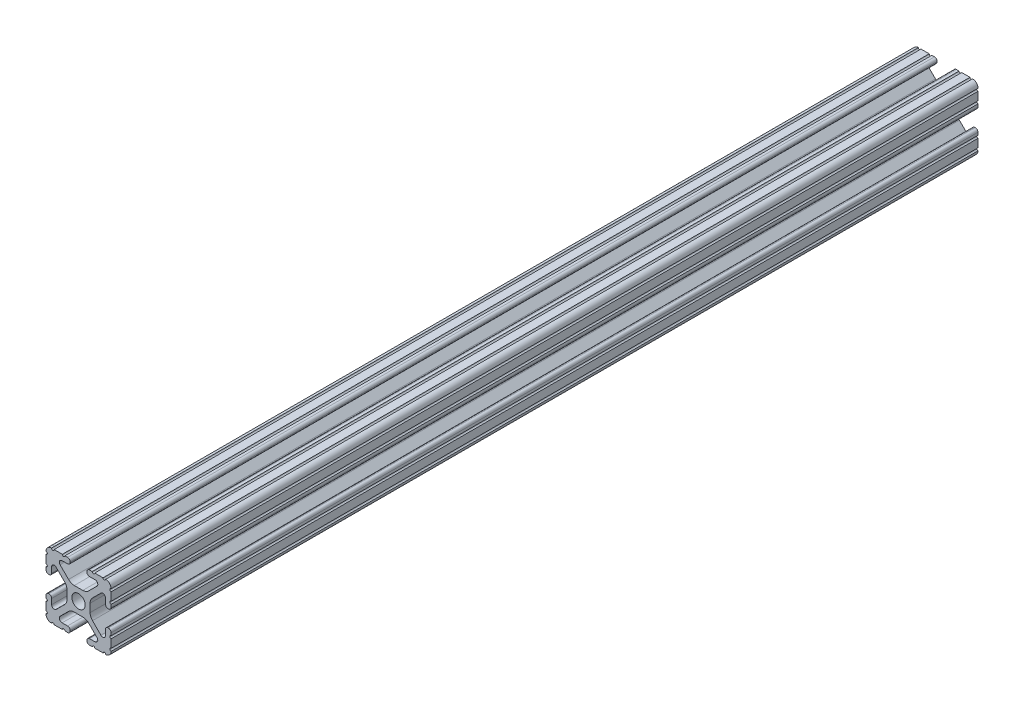
from build123d import *

# Parameters (mm, degrees)
SKETCH1_R               = 2.6035
BOSS_EXTRUDE1_DEPTH     = 457.2
CUT_EXTRUDE2_DEPTH      = 4.318
CUT_EXTRUDE2_DEPTH_BACK = 26.924
SKETCH4_W               = 324.910304918
SKETCH4_H               = 30.197320423
CUT_EXTRUDE3_DEPTH      = 1
CUT_EXTRUDE3_DEPTH_BACK = 26.4


with BuildPart() as part:
    # Sketch1 → Boss-Extrude1 (new body, symmetric)
    with BuildSketch(Plane.XY):
        with BuildLine():
            Line((-7.179650497, -8.645192506), (-3.952270251, -5.423690499))
            ThreePointArc((-3.952270251, -5.423690499), (-2.922936451, -4.736929036), (-1.709253557, -4.4958))
            Line((-1.709253557, -4.4958), (1.709253557, -4.4958))
            ThreePointArc((1.709253557, -4.4958), (2.922936451, -4.736929036), (3.952270251, -5.423690499))
            Line((3.952270251, -5.423690499), (7.179650497, -8.645192506))
            ThreePointArc((7.179650497, -8.645192506), (7.41473083, -9.822813117), (6.416408329, -10.4902))
            Line((6.416408329, -10.4902), (4.287512407, -10.4902))
            ThreePointArc((4.287512407, -10.4902), (3.54574862, -10.79744862), (3.2385, -11.539212407))
            Line((3.2385, -11.539212407), (3.2385, -11.650987593))
            ThreePointArc((3.2385, -11.650987593), (3.54574862, -12.39275138), (4.287512407, -12.7))
            Line((4.287512407, -12.7), (5.317126718, -12.7))
            ThreePointArc((5.317126718, -12.7), (5.825126718, -12.192), (6.333126718, -12.7))
            Line((6.333126718, -12.7), (9.550443118, -12.7))
            ThreePointArc((9.550443118, -12.7), (10.058366869, -12.192000006), (10.566443095, -12.699847501))
            ThreePointArc((10.566443095, -12.699847501), (12.082537762, -12.08250727), (12.699846982, -10.566399977))
            ThreePointArc((12.699846982, -10.566399977), (12.192000006, -10.058323491), (12.7, -9.5504))
            Line((12.7, -9.5504), (12.7, -6.3330836))
            ThreePointArc((12.7, -6.3330836), (12.192, -5.8250836), (12.7, -5.3170836))
            Line((12.7, -5.3170836), (12.7, -4.287469289))
            ThreePointArc((12.7, -4.287469289), (12.39275138, -3.545705502), (11.650987593, -3.238456882))
            Line((11.650987593, -3.238456882), (11.539212407, -3.238456882))
            ThreePointArc((11.539212407, -3.238456882), (10.79744862, -3.545705502), (10.4902, -4.287469289))
            Line((10.4902, -4.287469289), (10.4902, -6.402089023))
            ThreePointArc((10.4902, -6.402089023), (9.856505071, -7.351067942), (8.737131347, -7.129408934))
            Line((8.737131347, -7.129408934), (5.441005833, -3.840816462))
            ThreePointArc((5.441005833, -3.840816462), (4.750877967, -2.809883091), (4.5085, -1.593185507))
            Line((4.5085, -1.593185507), (4.5085, 1.593185507))
            ThreePointArc((4.5085, 1.593185507), (4.750877967, 2.809883091), (5.441005833, 3.840816462))
            Line((5.441005833, 3.840816462), (8.737131347, 7.129408934))
            ThreePointArc((8.737131347, 7.129408934), (9.856505071, 7.351067942), (10.4902, 6.402089023))
            Line((10.4902, 6.402089023), (10.4902, 4.287469289))
            ThreePointArc((10.4902, 4.287469289), (10.79744862, 3.545705502), (11.539212407, 3.238456882))
            Line((11.539212407, 3.238456882), (11.650987593, 3.238456882))
            ThreePointArc((11.650987593, 3.238456882), (12.39275138, 3.545705502), (12.7, 4.287469289))
            Line((12.7, 4.287469289), (12.7, 5.3170836))
            ThreePointArc((12.7, 5.3170836), (12.192, 5.8250836), (12.7, 6.3330836))
            Line((12.7, 6.3330836), (12.7, 9.5504))
            ThreePointArc((12.7, 9.5504), (12.192000006, 10.058323491), (12.699846982, 10.566399977))
            ThreePointArc((12.699846982, 10.566399977), (12.082537762, 12.08250727), (10.566443095, 12.699847501))
            ThreePointArc((10.566443095, 12.699847501), (10.058366869, 12.192000006), (9.550443118, 12.7))
            Line((9.550443118, 12.7), (6.333126718, 12.7))
            ThreePointArc((6.333126718, 12.7), (5.825126718, 12.192), (5.317126718, 12.7))
            Line((5.317126718, 12.7), (4.287512407, 12.7))
            ThreePointArc((4.287512407, 12.7), (3.54574862, 12.39275138), (3.2385, 11.650987593))
            Line((3.2385, 11.650987593), (3.2385, 11.539212407))
            ThreePointArc((3.2385, 11.539212407), (3.54574862, 10.79744862), (4.287512407, 10.4902))
            Line((4.287512407, 10.4902), (6.476788598, 10.4902))
            ThreePointArc((6.476788598, 10.4902), (7.432222385, 9.85140422), (7.207036008, 8.724370562))
            Line((7.207036008, 8.724370562), (3.898272566, 5.423169045))
            ThreePointArc((3.898272566, 5.423169045), (2.869120213, 4.736787962), (1.655778399, 4.4958))
            Line((1.655778399, 4.4958), (-1.655778399, 4.4958))
            ThreePointArc((-1.655778399, 4.4958), (-2.869120213, 4.736787962), (-3.898272566, 5.423169045))
            Line((-3.898272566, 5.423169045), (-7.207036008, 8.724370562))
            ThreePointArc((-7.207036008, 8.724370562), (-7.432222385, 9.85140422), (-6.476788598, 10.4902))
            Line((-6.476788598, 10.4902), (-4.287512407, 10.4902))
            ThreePointArc((-4.287512407, 10.4902), (-3.54574862, 10.79744862), (-3.2385, 11.539212407))
            Line((-3.2385, 11.539212407), (-3.2385, 11.650987593))
            ThreePointArc((-3.2385, 11.650987593), (-3.54574862, 12.39275138), (-4.287512407, 12.7))
            Line((-4.287512407, 12.7), (-5.317126718, 12.7))
            ThreePointArc((-5.317126718, 12.7), (-5.825126718, 12.192), (-6.333126718, 12.7))
            Line((-6.333126718, 12.7), (-9.550443118, 12.7))
            ThreePointArc((-9.550443118, 12.7), (-10.058366869, 12.192000006), (-10.566443095, 12.699847501))
            ThreePointArc((-10.566443095, 12.699847501), (-12.082537762, 12.08250727), (-12.699846982, 10.566399977))
            ThreePointArc((-12.699846982, 10.566399977), (-12.192000006, 10.058323491), (-12.7, 9.5504))
            Line((-12.7, 9.5504), (-12.7, 6.3330836))
            ThreePointArc((-12.7, 6.3330836), (-12.192, 5.8250836), (-12.7, 5.3170836))
            Line((-12.7, 5.3170836), (-12.7, 4.287469289))
            ThreePointArc((-12.7, 4.287469289), (-12.39275138, 3.545705502), (-11.650987593, 3.238456882))
            Line((-11.650987593, 3.238456882), (-11.539212407, 3.238456882))
            ThreePointArc((-11.539212407, 3.238456882), (-10.79744862, 3.545705502), (-10.4902, 4.287469289))
            Line((-10.4902, 4.287469289), (-10.4902, 6.402089023))
            ThreePointArc((-10.4902, 6.402089023), (-9.856505071, 7.351067942), (-8.737131347, 7.129408934))
            Line((-8.737131347, 7.129408934), (-5.441005833, 3.840816462))
            ThreePointArc((-5.441005833, 3.840816462), (-4.750877967, 2.809883091), (-4.5085, 1.593185507))
            Line((-4.5085, 1.593185507), (-4.5085, -1.593185507))
            ThreePointArc((-4.5085, -1.593185507), (-4.750877967, -2.809883091), (-5.441005833, -3.840816462))
            Line((-5.441005833, -3.840816462), (-8.737131347, -7.129408934))
            ThreePointArc((-8.737131347, -7.129408934), (-9.856505071, -7.351067942), (-10.4902, -6.402089023))
            Line((-10.4902, -6.402089023), (-10.4902, -4.287469289))
            ThreePointArc((-10.4902, -4.287469289), (-10.79744862, -3.545705502), (-11.539212407, -3.238456882))
            Line((-11.539212407, -3.238456882), (-11.650987593, -3.238456882))
            ThreePointArc((-11.650987593, -3.238456882), (-12.39275138, -3.545705502), (-12.7, -4.287469289))
            Line((-12.7, -4.287469289), (-12.7, -5.3170836))
            ThreePointArc((-12.7, -5.3170836), (-12.192, -5.8250836), (-12.7, -6.3330836))
            Line((-12.7, -6.3330836), (-12.7, -9.5504))
            ThreePointArc((-12.7, -9.5504), (-12.192000006, -10.058323491), (-12.699846982, -10.566399977))
            ThreePointArc((-12.699846982, -10.566399977), (-12.082537762, -12.08250727), (-10.566443095, -12.699847501))
            ThreePointArc((-10.566443095, -12.699847501), (-10.058366869, -12.192000006), (-9.550443118, -12.7))
            Line((-9.550443118, -12.7), (-6.333126718, -12.7))
            ThreePointArc((-6.333126718, -12.7), (-5.825126718, -12.192), (-5.317126718, -12.7))
            Line((-5.317126718, -12.7), (-4.287512407, -12.7))
            ThreePointArc((-4.287512407, -12.7), (-3.54574862, -12.39275138), (-3.2385, -11.650987593))
            Line((-3.2385, -11.650987593), (-3.2385, -11.539212407))
            ThreePointArc((-3.2385, -11.539212407), (-3.54574862, -10.79744862), (-4.287512407, -10.4902))
            Line((-4.287512407, -10.4902), (-6.416408329, -10.4902))
            ThreePointArc((-6.416408329, -10.4902), (-7.41473083, -9.822813117), (-7.179650497, -8.645192506))
        make_face()
        Circle(SKETCH1_R, mode=Mode.SUBTRACT)
    extrude(amount=BOSS_EXTRUDE1_DEPTH, both=True)

    # Sketch3 → Cut-Extrude2 (cut, two sides)
    with BuildSketch(Plane.ZY.offset(12.7)) as cut_extrude2_sk:
        Polygon((-203.2, -27.552777595), (-203.2, 21.158109763), (-461.090893327, 21.158109763), (-461.090893327, -25.4), align=None)
    extrude(amount=CUT_EXTRUDE2_DEPTH, mode=Mode.SUBTRACT)
    extrude(cut_extrude2_sk.sketch, amount=-CUT_EXTRUDE2_DEPTH_BACK, mode=Mode.SUBTRACT)

    # Sketch4 → Cut-Extrude3 (cut, two sides)
    with BuildSketch(Plane(origin=(12.7, 0, 0), x_dir=(0, 0, -1), z_dir=(1, 0, 0))) as cut_extrude3_sk:
        with Locations((43.51312076, -0.091464018)):
            Rectangle(SKETCH4_W, SKETCH4_H)
    extrude(amount=CUT_EXTRUDE3_DEPTH, mode=Mode.SUBTRACT)
    extrude(cut_extrude3_sk.sketch, amount=-CUT_EXTRUDE3_DEPTH_BACK, mode=Mode.SUBTRACT)


solid = part.part
